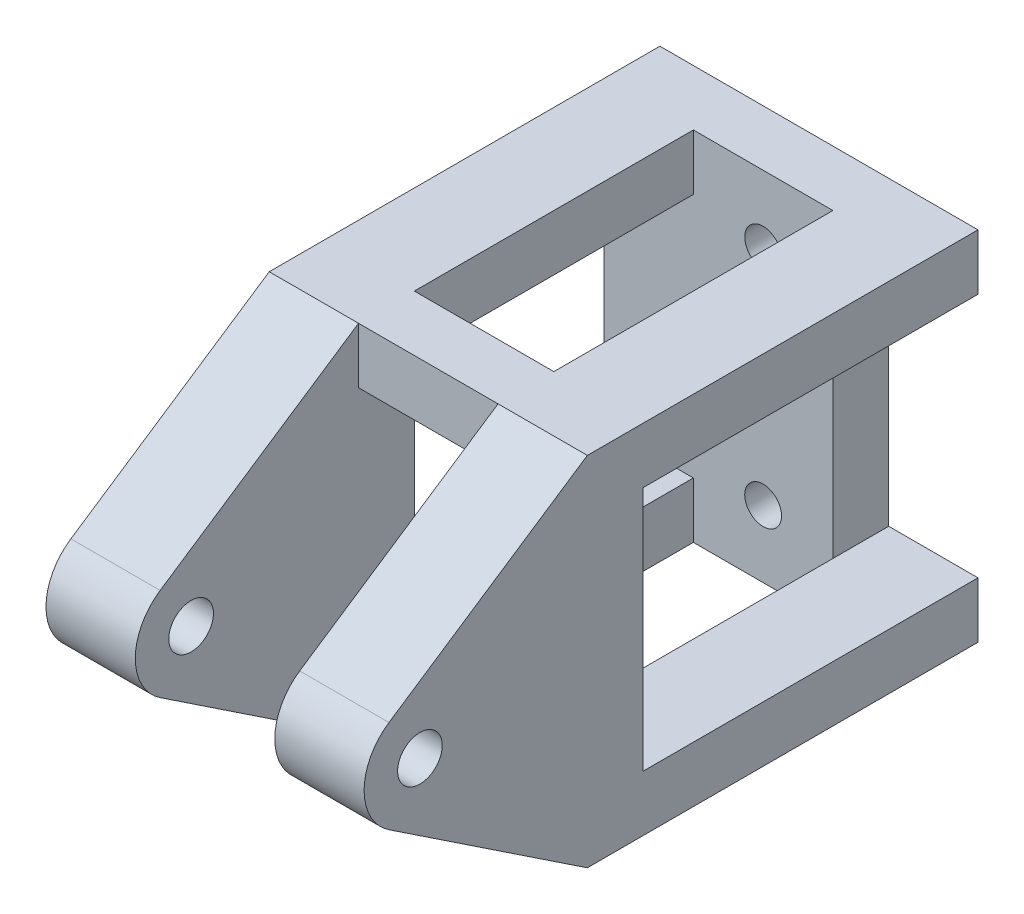
from build123d import *

# Parameters (mm, degrees)
SKETCH_1_W          = 28.5
SKETCH_1_H          = 32
EXTRUDE_1_DEPTH     = 5
SKETCH_3_R          = 2
EXTRUDE_2_DEPTH     = 8
SKETCH_4_R          = 1.65
CUT_EXTRUDE_1_DEPTH = 6
SKETCH_5_R          = 1.65
CUT_EXTRUDE_2_DEPTH = 5
SKETCH_6_W          = 25
SKETCH_6_H          = 22
CUT_EXTRUDE_3_DEPTH = 29.5
EXTRUDE_3_REACH     = 22.5
SKETCH_7_W          = 5
SKETCH_7_H          = 5
SKETCH_8_W          = 8
SKETCH_8_H          = 22
CUT_EXTRUDE_4_DEPTH = 10


with BuildPart() as part:
    # ｽｹｯﾁ1 → ﾎﾞｽ - 押し出し1 (new body)
    with BuildSketch(Plane.XY):
        Rectangle(SKETCH_1_W, SKETCH_1_H)
    extrude(amount=EXTRUDE_1_DEPTH)

    # ｽｹｯﾁ3 → ﾎﾞｽ - 押し出し2 (add)
    with BuildSketch(Plane(origin=(14.25, 0, 0), x_dir=(0, 0, -1), z_dir=(1, 0, 0))):
        with BuildLine():
            Line((-5, 16), (-35, 16))
            Line((-35, 16), (-52.772001082, 4.161251014))
            ThreePointArc((-52.772001082, 4.161251014), (-55, 0), (-52.772001082, -4.161251014))
            Line((-52.772001082, -4.161251014), (-35, -16))
            Line((-35, -16), (-5, -16))
            Line((-5, -16), (-5, 16))
        make_face()
        with Locations((-50, 0)):
            Circle(SKETCH_3_R, mode=Mode.SUBTRACT)
    extrude_2 = extrude(amount=-EXTRUDE_2_DEPTH)

    # ﾐﾗｰ1: ﾎﾞｽ - 押し出し2 across plane
    add(extrude_2.mirror(Plane(origin=(0, 0, 0), x_dir=(0, 0, 1), z_dir=(1, 0, 0))))

    # ｽｹｯﾁ4 → ｶｯﾄ - 押し出し1 (cut, through all)
    with BuildSketch(Plane.XY.offset(5)):
        with Locations((0, 10)):
            Circle(SKETCH_4_R)
        with Locations((0, -10)):
            Circle(SKETCH_4_R)
    extrude(amount=-CUT_EXTRUDE_1_DEPTH, mode=Mode.SUBTRACT)

    # ｽｹｯﾁ5 → ｶｯﾄ - 押し出し2 (cut)
    with BuildSketch(Plane.XY):
        with Locations((12.35, -5)):
            Circle(SKETCH_5_R)
        with Locations((12.35, 5)):
            Circle(SKETCH_5_R)
    extrude(amount=CUT_EXTRUDE_2_DEPTH, mode=Mode.SUBTRACT)

    # ｽｹｯﾁ6 → ｶｯﾄ - 押し出し3 (cut, through all)
    with BuildSketch(Plane(origin=(14.25, 0, 0), x_dir=(0, 0, -1), z_dir=(1, 0, 0))):
        with Locations((-17.5, 0)):
            Rectangle(SKETCH_6_W, SKETCH_6_H)
    extrude(amount=-CUT_EXTRUDE_3_DEPTH, mode=Mode.SUBTRACT)

    # ｽｹｯﾁ7 → ﾎﾞｽ - 押し出し3 (add, up to next)
    with BuildSketch(Plane(origin=(-6.25, 0, 0), x_dir=(0, 0, -1), z_dir=(1, 0, 0)), mode=Mode.PRIVATE) as extrude_3_sk1:
        with Locations((-32.5, 13.5)):
            Rectangle(SKETCH_7_W, SKETCH_7_H)
    extrude_3_tool1 = extrude(extrude_3_sk1.sketch, amount=EXTRUDE_3_REACH, mode=Mode.PRIVATE) - part.part
    add(extrude_3_tool1.solids().sort_by_distance((-6.25, 13.5, 32.5))[0])
    # ｽｹｯﾁ7 → ﾎﾞｽ - 押し出し3 (add, up to next)
    with BuildSketch(Plane(origin=(-6.25, 0, 0), x_dir=(0, 0, -1), z_dir=(1, 0, 0)), mode=Mode.PRIVATE) as extrude_3_sk2:
        with Locations((-32.5, -13.5)):
            Rectangle(SKETCH_7_W, SKETCH_7_H)
    extrude_3_tool2 = extrude(extrude_3_sk2.sketch, amount=EXTRUDE_3_REACH, mode=Mode.PRIVATE) - part.part
    add(extrude_3_tool2.solids().sort_by_distance((-6.25, -13.5, 32.5))[0])

    # ｽｹｯﾁ8 → ｶｯﾄ - 押し出し4 (cut)
    with BuildSketch(Plane(origin=(0, 0, 0), x_dir=(-1, 0, 0), z_dir=(0, 0, -1))):
        with Locations((-10.25, 0)):
            Rectangle(SKETCH_8_W, SKETCH_8_H)
    extrude(amount=-CUT_EXTRUDE_4_DEPTH, mode=Mode.SUBTRACT)


solid = part.part
